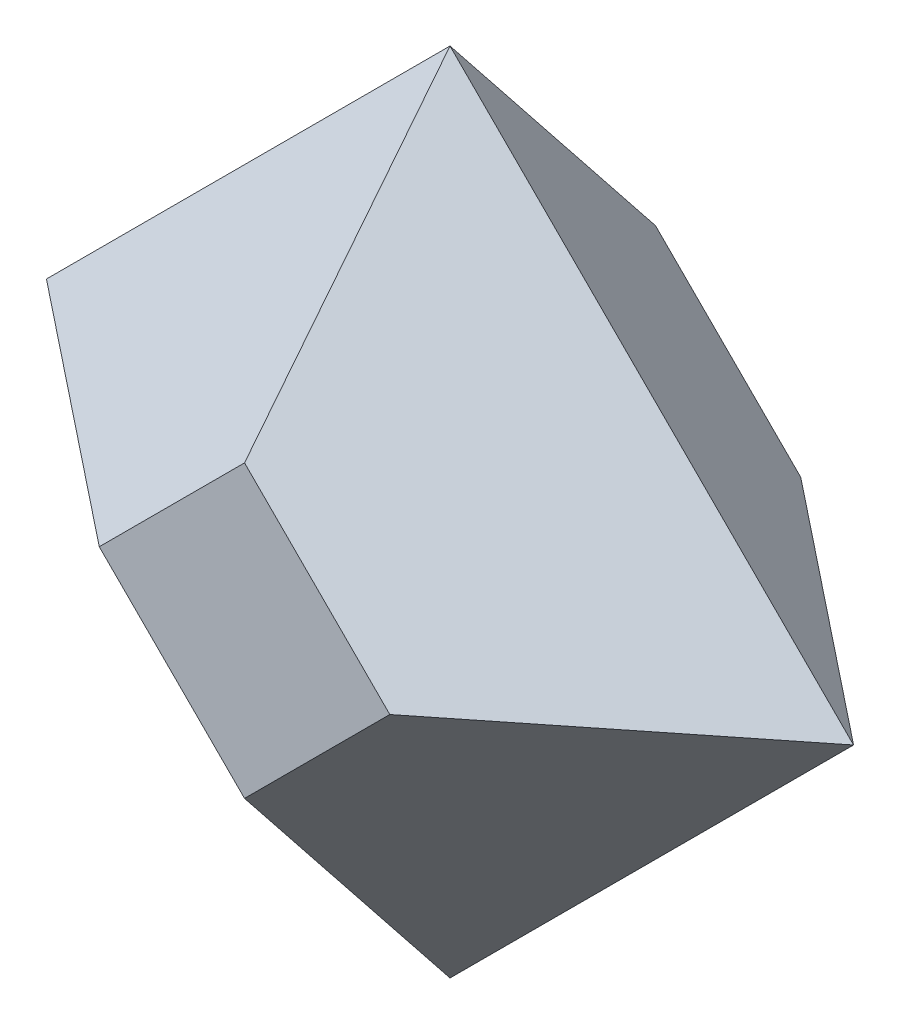
from build123d import *


with BuildPart() as part:
    # Croquis1 → Recubrir1 section 0
    with BuildSketch(Plane.XY):
        Polygon((0, 17.67766953), (-17.67766953, 0), (0, -17.67766953), (17.67766953, 0), align=None)
    # Croquis2 → Recubrir1 section 1
    with BuildSketch(Plane.XY.offset(9)):
        Polygon((0, 6.363961031), (-6.363961031, 0), (0, -6.363961031), (6.363961031, 0), align=None)
    loft()

    # Croquis5 → Recubrir2 section 0
    with BuildSketch(Plane(origin=(0, 0, 0), x_dir=(-1, 0, 0), z_dir=(0, 0, -1))):
        Polygon((0, 17.67766953), (-17.67766953, 0), (0, -17.67766953), (17.67766953, 0), align=None)
    # Croquis4 → Recubrir2 section 1
    with BuildSketch(Plane(origin=(0, 0, -9), x_dir=(-1, 0, 0), z_dir=(0, 0, -1))):
        Polygon((0, -6.363961031), (6.363961031, 0), (0, 6.363961031), (-6.363961031, 0), align=None)
    loft()


solid = part.part
